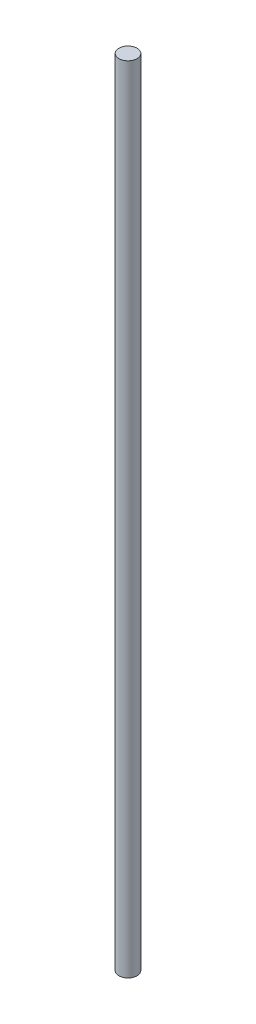
from build123d import *

# Parameters (mm, degrees)
SKETCH1_R           = 4
BOSS_EXTRUDE1_DEPTH = 350.52


with BuildPart() as part:
    # Sketch1 → Boss-Extrude1 (new body)
    with BuildSketch(Plane(origin=(0, 0, 0), x_dir=(1, 0, 0), z_dir=(0, 1, 0))):
        Circle(SKETCH1_R)
    extrude(amount=BOSS_EXTRUDE1_DEPTH)


solid = part.part
